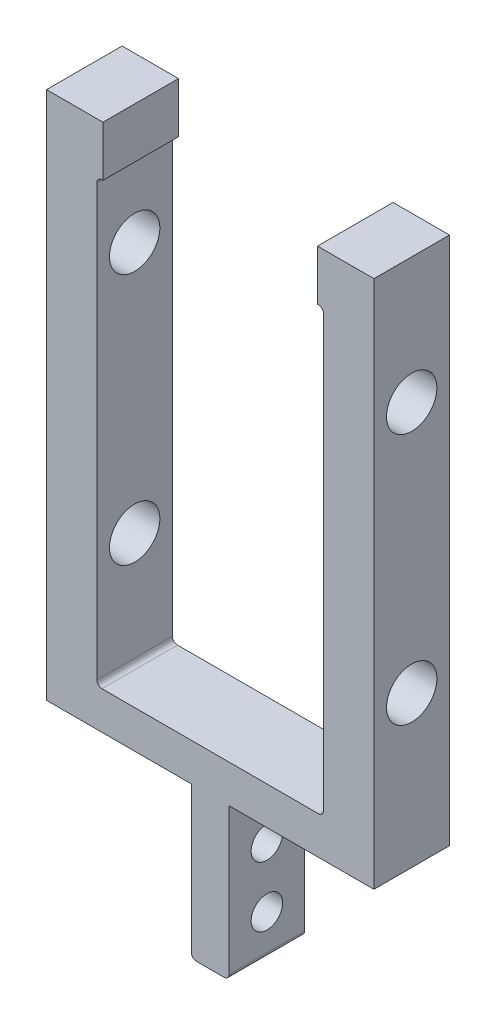
from build123d import *

# Parameters (mm, degrees)
BOSS_EXTRUDE1_DEPTH = 9.525
SKETCH2_R           = 6.35
CUT_EXTRUDE1_DEPTH  = 83.55
FILLET1_R           = 1.27
HOLE1_D             = 7.94512
HOLE1_DEPTH         = 46.0375
HOLE1_TIP           = 2.386954861


with BuildPart() as part:
    # Sketch1 → Boss-Extrude1 (new body, symmetric)
    with BuildSketch(Plane.XY):
        Polygon((4.7625, 0), (-4.7625, 0), (-4.7625, 38.1), (-41.275, 38.1), (-41.275, 171.45), (-27.051, 171.45), (-27.051, 158.75), (-28.575, 158.75), (-28.575, 47.625), (28.575, 47.625), (28.575, 158.75), (27.051, 158.75), (27.051, 171.45), (41.275, 171.45), (41.275, 38.1), (4.7625, 38.1), align=None)
    extrude(amount=BOSS_EXTRUDE1_DEPTH, both=True)

    # Sketch2 → Cut-Extrude1 (cut, through all)
    with BuildSketch(Plane.ZY.offset(41.275)):
        with Locations((0, 76.2)):
            Circle(SKETCH2_R)
        with Locations((0, 139.7)):
            Circle(SKETCH2_R)
    extrude(amount=-CUT_EXTRUDE1_DEPTH, mode=Mode.SUBTRACT)

    # Fillet1
    fillet1_edges = [part.edges().sort_by_distance(p)[0] for p in [
        (4.7625, 0, 0),
        (-4.7625, 0, 0),
        (-28.575, 158.75, 0),
        (-28.575, 47.625, 0),
        (28.575, 47.625, 0),
        (28.575, 158.75, 0),
    ]]
    fillet(fillet1_edges, radius=FILLET1_R)

    # Hole1
    with Locations(Plane(origin=(4.7625, 0, 0), x_dir=(0, 0, 1), z_dir=(1, 0, 0))):
        with Locations((0, -25.4), (0, -10.16)):
            Hole(HOLE1_D / 2, depth=HOLE1_DEPTH)
            with Locations((0, 0, -(HOLE1_DEPTH + HOLE1_TIP / 2))):  # 118° drill point
                Cone(0, HOLE1_D / 2, HOLE1_TIP, mode=Mode.SUBTRACT)


solid = part.part
